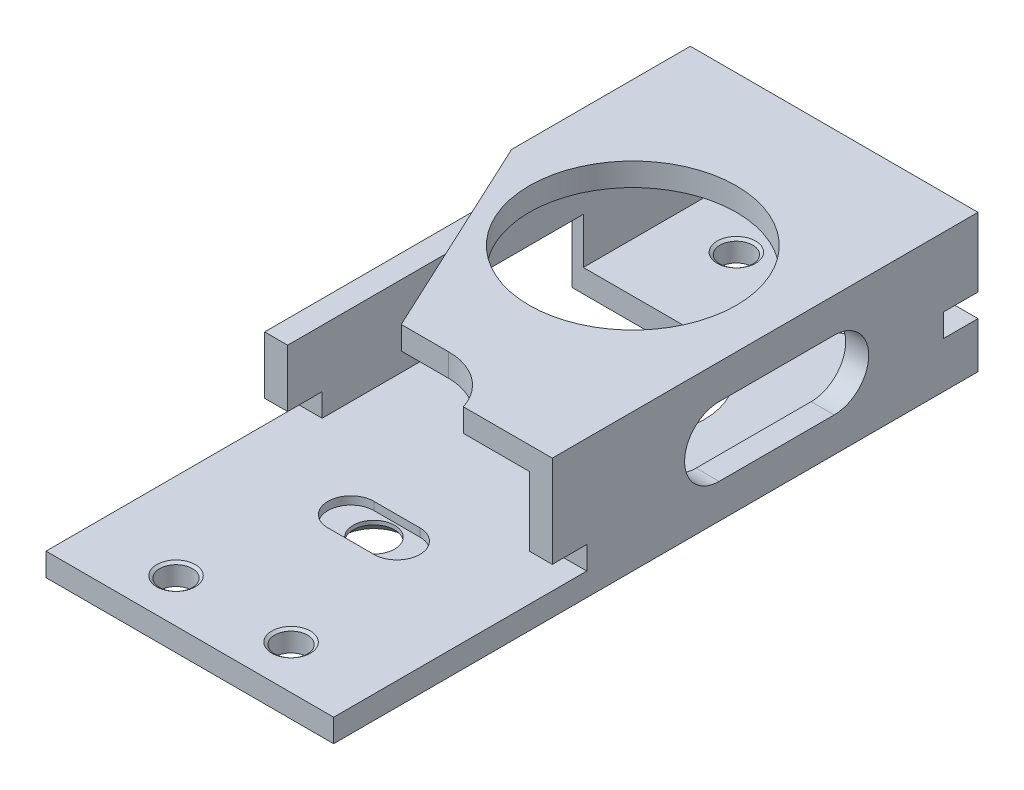
from build123d import *

# Parameters (mm, degrees)
SKETCH_1_W                    = 25
SKETCH_1_H                    = 12
SKETCH_1_W_2                  = 21
SKETCH_1_H_2                  = 8
EXTRUDE_1_DEPTH               = 56
CUT_EXTRUDE_1_REACH           = 14
SKETCH_2_R                    = 9
HOLE_WIZARD_4_40_1_AT_2_COUNT = 2
HOLE_WIZARD_4_40_1_AT_2_PITCH = 48.7
HOLE_WIZARD_4_40_1_AT_3_COUNT = 2
HOLE_WIZARD_4_40_1_AT_3_PITCH = 49.716093974
HOLE_WIZARD_4_40_1_AT_4_COUNT = 2
HOLE_WIZARD_4_40_1_AT_4_PITCH = 10
CUT_EXTRUDE_2_DEPTH           = 6
CUT_EXTRUDE_4_DEPTH           = 1
SKETCH_9_W                    = 25
SKETCH_9_H                    = 19
CUT_EXTRUDE_7_DEPTH           = 10
CUT_EXTRUDE_8_REACH           = 27
CUT_EXTRUDE_9_DEPTH           = 3
SKETCH_15_W                   = 3
SKETCH_15_H                   = 2
CUT_EXTRUDE_10_DEPTH          = 26
HOLE_WIZARD_M31_D             = 3.6
HOLE_WIZARD_M31_CSINK_D       = 5.5
HOLE_WIZARD_M31_CSINK_ANGLE   = 90
CUT_EXTRUDE_11_DEPTH          = 0.7


with BuildPart() as part:
    # Sketch 1 → Extrude 1 (new body)
    with BuildSketch(Plane.XY):
        Rectangle(SKETCH_1_W, SKETCH_1_H)
        Rectangle(SKETCH_1_W_2, SKETCH_1_H_2, mode=Mode.SUBTRACT)
    extrude(amount=EXTRUDE_1_DEPTH)

    # Sketch 2 → Cut-Extrude 1 (cut, up to next)
    with BuildSketch(Plane(origin=(0, 6, 0), x_dir=(1, 0, 0), z_dir=(0, 1, 0)), mode=Mode.PRIVATE) as cut_extrude_1_sk1:
        with Locations((0, -17.5)):
            Circle(SKETCH_2_R)
    cut_extrude_1_tool1 = extrude(cut_extrude_1_sk1.sketch, amount=-CUT_EXTRUDE_1_REACH, mode=Mode.PRIVATE) & part.part
    add(cut_extrude_1_tool1.solids().sort_by_distance((0, 6, 17.5))[0], mode=Mode.SUBTRACT)

    # Sketch 3 → Hole Wizard 4-40 - 1 (revolve, cut)
    with BuildSketch(Plane(origin=(5, -6, 52.2), x_dir=(0, 0, -1), z_dir=(1, 0, 0))):
        Polygon((0, 0), (0, 2), (1.6764, 2), (1.4224, 1.822147285), (1.4224, 0.177852715), (1.6764, 0), align=None)
    hole_wizard_4_40_1 = revolve(axis=Axis((5, -12.35, 52.2), (0, 1, 0)), mode=Mode.SUBTRACT)

    # Hole Wizard 4-40 - 1 at 2: Hole Wizard 4-40 - 1 ×2
    with Locations(*[(0, 0, -i * HOLE_WIZARD_4_40_1_AT_2_PITCH) for i in range(1, HOLE_WIZARD_4_40_1_AT_2_COUNT)]):
        add(hole_wizard_4_40_1, mode=Mode.SUBTRACT)

    # Hole Wizard 4-40 - 1 at 3: Hole Wizard 4-40 - 1 ×2
    with Locations(*[Vector(-0.201142109, 0, -0.979562072) * (i * HOLE_WIZARD_4_40_1_AT_3_PITCH) for i in range(1, HOLE_WIZARD_4_40_1_AT_3_COUNT)]):
        add(hole_wizard_4_40_1, mode=Mode.SUBTRACT)

    # Hole Wizard 4-40 - 1 at 4: Hole Wizard 4-40 - 1 ×2
    with Locations(*[(-i * HOLE_WIZARD_4_40_1_AT_4_PITCH, 0, 0) for i in range(1, HOLE_WIZARD_4_40_1_AT_4_COUNT)]):
        add(hole_wizard_4_40_1, mode=Mode.SUBTRACT)

    # Sketch 5 → Cut-Extrude 2 (cut)
    with BuildSketch(Plane.XZ.offset(6)):
        with BuildLine():
            Line((-12.5, 23.7), (-12.5, 11.3))
            Line((-12.5, 11.3), (0, 11.3))
            ThreePointArc((0, 11.3), (6.2, 17.5), (0, 23.7))
            Line((0, 23.7), (-12.5, 23.7))
        make_face()
    extrude(amount=-CUT_EXTRUDE_2_DEPTH, mode=Mode.SUBTRACT)

    # Sketch 8 → Cut-Extrude 4 (cut)
    with BuildSketch(Plane.ZY.offset(12.5)):
        with BuildLine():
            Line((9.3, -6), (9.3, -2))
            ThreePointArc((9.3, -2), (10.178679656, 0.121320344), (12.3, 1))
            Line((12.3, 1), (22.3, 1))
            ThreePointArc((22.3, 1), (24.421320344, 0.121320344), (25.3, -2))
            Line((25.3, -2), (25.3, -6))
            Line((25.3, -6), (9.3, -6))
        make_face()
    extrude(amount=-CUT_EXTRUDE_4_DEPTH, mode=Mode.SUBTRACT)

    # Sketch 9 → Cut-Extrude 7 (cut)
    with BuildSketch(Plane(origin=(0, 6, 0), x_dir=(1, 0, 0), z_dir=(0, 1, 0))):
        with Locations((0, -46.5)):
            Rectangle(SKETCH_9_W, SKETCH_9_H)
    extrude(amount=-CUT_EXTRUDE_7_DEPTH, mode=Mode.SUBTRACT)

    # Sketch 13 → Cut-Extrude 8 (cut, up to next)
    with BuildSketch(Plane(origin=(12.5, 0, 0), x_dir=(0, 0, -1), z_dir=(1, 0, 0)), mode=Mode.PRIVATE) as cut_extrude_8_sk1:
        with BuildLine():
            Line((-22.5, 3), (-12.5, 3))
            ThreePointArc((-12.5, 3), (-9.5, 0), (-12.5, -3))
            Line((-12.5, -3), (-22.5, -3))
            ThreePointArc((-22.5, -3), (-25.5, 0), (-22.5, 3))
        make_face()
    cut_extrude_8_tool1 = extrude(cut_extrude_8_sk1.sketch, amount=-CUT_EXTRUDE_8_REACH, mode=Mode.PRIVATE) & part.part
    add(cut_extrude_8_tool1.solids().sort_by_distance((12.5, 0, 17.5))[0], mode=Mode.SUBTRACT)

    # Sketch 14 → Cut-Extrude 9 (cut)
    with BuildSketch(Plane(origin=(0, 6, 0), x_dir=(1, 0, 0), z_dir=(0, 1, 0))):
        with BuildLine():
            Line((-4.124545619, -33.5), (0, -33.5))
            ThreePointArc((0, -33.5), (2.958039892, -34.468871126), (4.769696007, -37))
            Line((4.769696007, -37), (-12.5, -37))
            Line((-12.5, -37), (-12.5, -15.538780117))
            Line((-12.5, -15.538780117), (-4.124545619, -33.5))
        make_face()
    extrude(amount=-CUT_EXTRUDE_9_DEPTH, mode=Mode.SUBTRACT)

    # Sketch 15 → Cut-Extrude 10 (cut, through all)
    with BuildSketch(Plane.ZY.offset(12.5)):
        with Locations((35.5, -3)):
            Rectangle(SKETCH_15_W, SKETCH_15_H)
        with Locations((1.5, -1)):
            Rectangle(SKETCH_15_W, SKETCH_15_H)
    extrude(amount=-CUT_EXTRUDE_10_DEPTH, mode=Mode.SUBTRACT)

    # Hole Wizard M31 (through all)
    with Locations(Plane.XZ.offset(6)):
        with Locations((0, 40)):
            CounterSinkHole(HOLE_WIZARD_M31_D / 2, HOLE_WIZARD_M31_CSINK_D / 2, counter_sink_angle=HOLE_WIZARD_M31_CSINK_ANGLE)

    # Sketch 18 → Cut-Extrude 11 (cut)
    with BuildSketch(Plane(origin=(0, -4, 0), x_dir=(1, 0, 0), z_dir=(0, 1, 0))):
        with BuildLine():
            Line((-2, -38), (2, -38))
            ThreePointArc((2, -38), (4, -40), (2, -42))
            Line((2, -42), (-2, -42))
            ThreePointArc((-2, -42), (-4, -40), (-2, -38))
        make_face()
    extrude(amount=-CUT_EXTRUDE_11_DEPTH, mode=Mode.SUBTRACT)


solid = part.part
